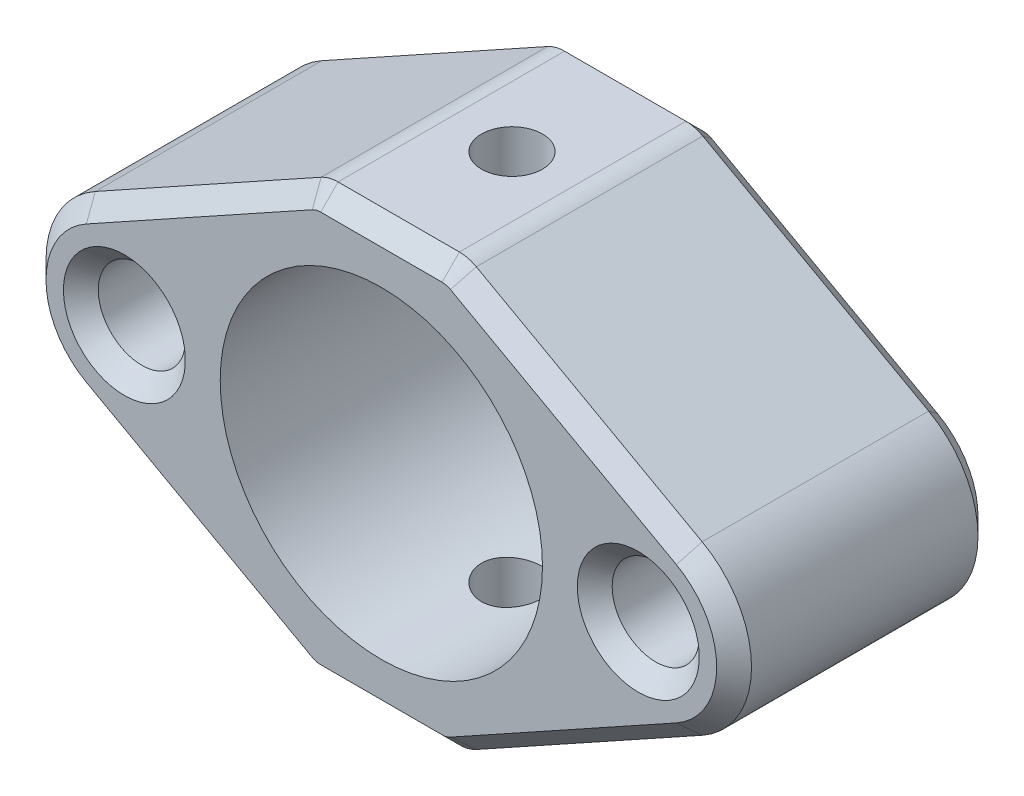
from build123d import *

# Parameters (mm, degrees)
SKETCH_1_R               = 9.25
SKETCH_1_R_2             = 2.5
EXTRUDE_1_DEPTH          = 7.5
SKETCH_3_R               = 1.75
CUT_EXTRUDE_1_DEPTH      = 13.25
CUT_EXTRUDE_1_DEPTH_BACK = 13.25
CHAMFER_1_SIZE           = 1
FILLET_1_R               = 2
CHAMFER_2_SIZE           = 1


with BuildPart() as part:
    # ｽｹｯﾁ1 → ﾎﾞｽ - 押し出し1 (new body, symmetric)
    with BuildSketch(Plane.XY):
        with BuildLine():
            Line((4, 12.25), (17.417201647, 4.809993282))
            ThreePointArc((17.417201647, 4.809993282), (20.25, 0), (17.417201647, -4.809993282))
            Line((17.417201647, -4.809993282), (4, -12.25))
            Line((4, -12.25), (-4, -12.25))
            Line((-4, -12.25), (-17.417201647, -4.809993282))
            ThreePointArc((-17.417201647, -4.809993282), (-20.25, 0), (-17.417201647, 4.809993282))
            Line((-17.417201647, 4.809993282), (-4, 12.25))
            Line((-4, 12.25), (4, 12.25))
        make_face()
        Circle(SKETCH_1_R, mode=Mode.SUBTRACT)
        with Locations((14.75, 0)):
            Circle(SKETCH_1_R_2, mode=Mode.SUBTRACT)
        with Locations((-14.75, 0)):
            Circle(SKETCH_1_R_2, mode=Mode.SUBTRACT)
    extrude(amount=EXTRUDE_1_DEPTH, both=True)

    # ｽｹｯﾁ3 → ｶｯﾄ - 押し出し1 (cut, two sides)
    with BuildSketch(Plane(origin=(0, 0, 0), x_dir=(1, 0, 0), z_dir=(0, 1, 0))) as cut_extrude_1_sk:
        Circle(SKETCH_3_R)
    extrude(amount=CUT_EXTRUDE_1_DEPTH, mode=Mode.SUBTRACT)
    extrude(cut_extrude_1_sk.sketch, amount=-CUT_EXTRUDE_1_DEPTH_BACK, mode=Mode.SUBTRACT)

    # 面取り1
    chamfer_1_edges = [part.edges().sort_by_distance(p)[0] for p in [
        (12.25, 0, -7.5),
        (12.25, 0, 7.5),
        (-17.25, 0, -7.5),
        (-17.25, 0, 7.5),
    ]]
    chamfer(chamfer_1_edges, length=CHAMFER_1_SIZE)

    # ﾌｨﾚｯﾄ1
    fillet_1_edges = [part.edges().sort_by_distance(p)[0] for p in [
        (4, -12.25, 0),
        (-4, -12.25, 0),
        (-4, 12.25, 0),
        (4, 12.25, 0),
    ]]
    fillet(fillet_1_edges, radius=FILLET_1_R)

    # 面取り2
    chamfer_2_edges = [part.edges().sort_by_distance(p)[0] for p in [
        (10.934845958, 8.404540874, -7.5),
        (20.25, 0, -7.5),
        (-20.25, 0, 7.5),
        (-10.934845958, -8.404540874, 7.5),
        (20.25, 0, 7.5),
        (10.934845958, -8.404540874, -7.5),
        (10.934845958, -8.404540874, 7.5),
        (0, -12.25, -7.5),
        (-10.934845958, 8.404540874, -7.5),
        (0, 12.25, -7.5),
        (-3.983509466, 12.186256302, -7.5),
        (3.983509466, 12.186256302, -7.5),
        (-3.983509466, -12.186256302, -7.5),
        (3.983509466, -12.186256302, -7.5),
        (0, -12.25, 7.5),
        (0, 12.25, 7.5),
        (-10.934845958, 8.404540874, 7.5),
        (-3.983509466, 12.186256302, 7.5),
        (3.983509466, 12.186256302, 7.5),
        (-3.983509466, -12.186256302, 7.5),
        (3.983509466, -12.186256302, 7.5),
        (10.934845958, 8.404540874, 7.5),
        (-10.934845958, -8.404540874, -7.5),
        (-20.25, 0, -7.5),
    ]]
    chamfer(chamfer_2_edges, length=CHAMFER_2_SIZE)


solid = part.part
